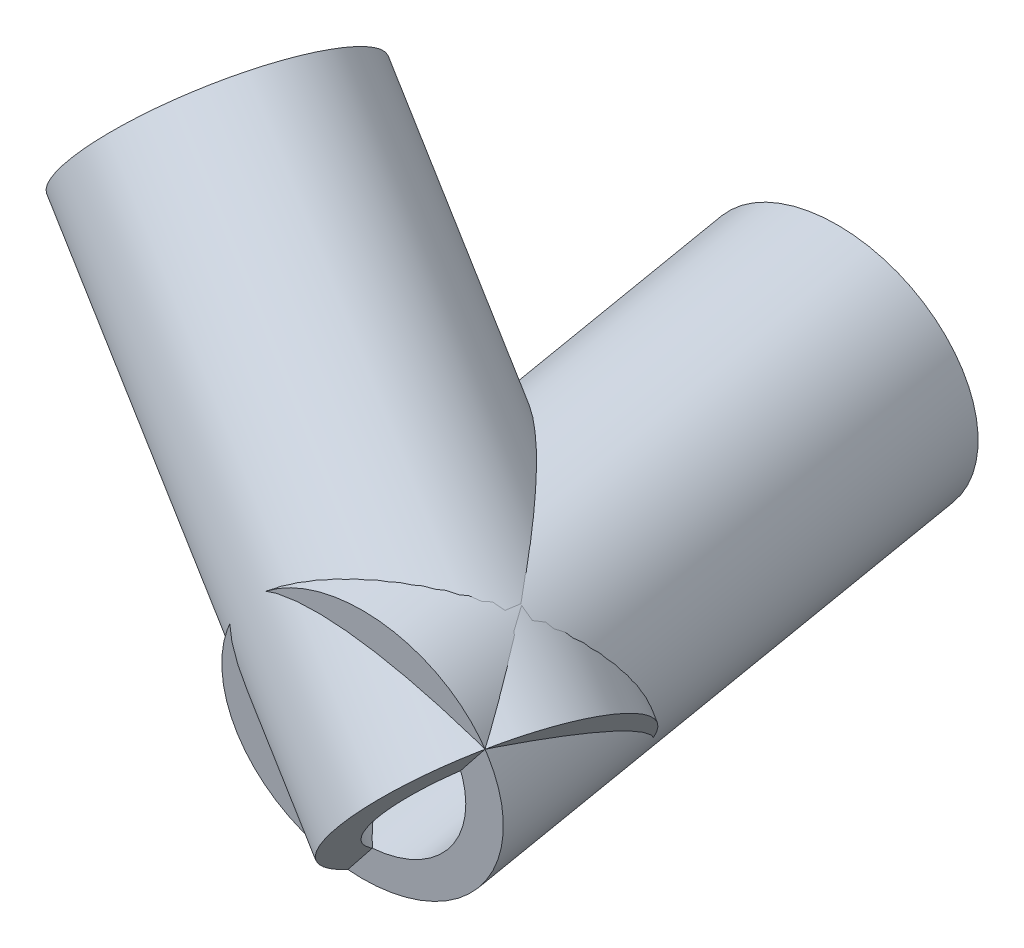
from build123d import *


with BuildPart() as part:
    # Sketch12 → Revolve3 (revolve)
    with BuildSketch(Plane(origin=(-33.509025336, 0, 2.690185958), x_dir=(-0.080024952, 0, -0.996792861), z_dir=(0.996792861, 0, -0.080024952))):
        Polygon((1.112690179, 14.915901713), (50.832362557, 20.203072847), (51.255336248, 16.225499056), (1.53566387, 10.938327923), (-8.408270606, 9.880893697), (-8.831244297, 13.858467487), align=None)
    revolve(axis=Axis((-33.725, 0, 0), (-0.079576288, 0.105743423, -0.991204289)))


with BuildPart() as body_2:
    # Sketch11 → Revolve2 (revolve)
    with BuildSketch(Plane(origin=(-3.019231595, 0, 9.628490334), x_dir=(-0.954188122, 0, -0.299207334), z_dir=(0.299207334, 0, -0.954188122))):
        Polygon((41.3942724, -11.836261273), (80.848476641, 18.877998732), (78.391335841, 22.034335072), (38.953432988, -8.667234648), (31.046290751, -14.822776934), (33.503431551, -17.979113274), align=None)
    revolve(axis=Axis((-33.725, 0, 0), (-0.752934661, 0.6142852, -0.236099745)))


solid = Compound([part.part, body_2.part])
